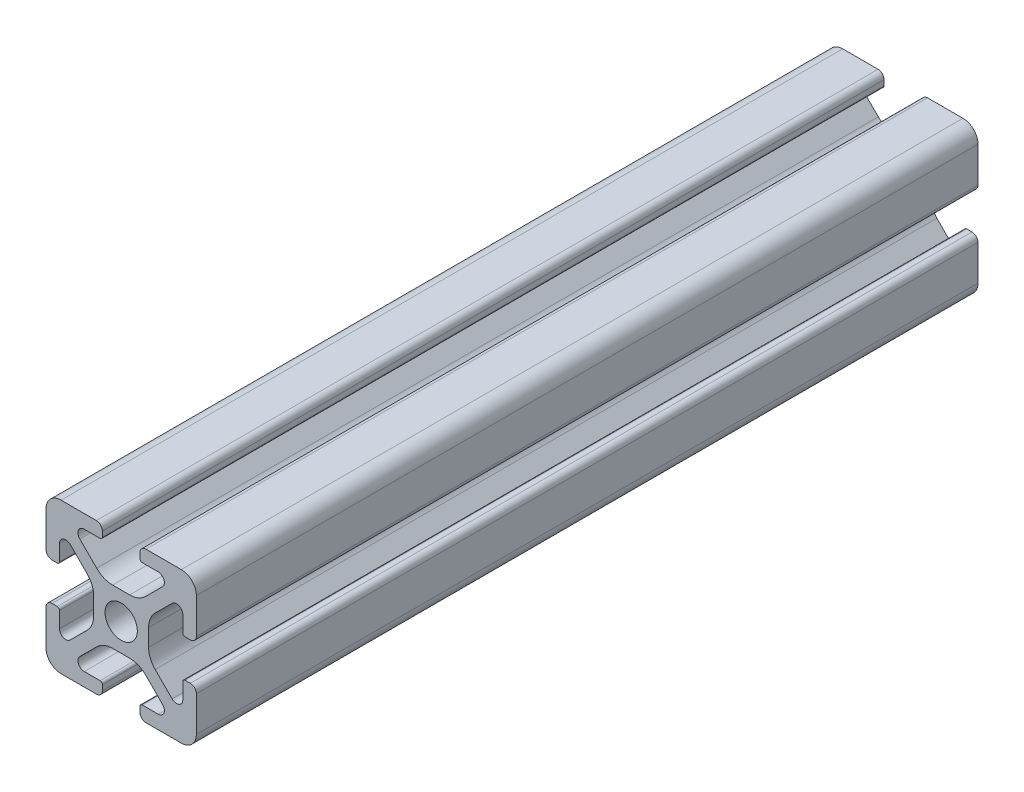
from build123d import *

# Parameters (mm, degrees)
SKIZZE1_R                       = 2.15
AUFSATZ_LINEAR_AUSTRAGEN1_DEPTH = 104


with BuildPart() as part:
    # Skizze1 → Aufsatz-Linear austragen1 (new body)
    with BuildSketch(Plane.XY.offset(100)):
        with BuildLine():
            Line((12.499999989, 1.499999999), (12.499999989, 0.800000002))
            ThreePointArc((12.499999989, 0.800000002), (12.734314564, 0.234314576), (13.299999991, 0))
            Line((13.299999991, 0), (18, 0))
            ThreePointArc((18, 0), (19.414213562, 0.585786438), (20, 2))
            Line((20, 2), (20, 6.700000003))
            ThreePointArc((20, 6.700000003), (19.765685425, 7.265685427), (19.2, 7.500000003))
            Line((19.2, 7.500000003), (18.499999995, 7.500000003))
            ThreePointArc((18.499999995, 7.500000003), (18.287867961, 7.412132037), (18.199999995, 7.200000003))
            Line((18.199999995, 7.200000003), (18.199999995, 5.082411607))
            ThreePointArc((18.199999995, 5.082411607), (17.686138517, 4.313363558), (16.778984491, 4.493807713))
            Line((16.778984491, 4.493807713), (14.528679651, 6.744112553))
            ThreePointArc((14.528679651, 6.744112553), (13.878361397, 7.717382599), (13.649999995, 8.865432896))
            Line((13.649999995, 8.865432896), (13.649999995, 11.134567106))
            ThreePointArc((13.649999995, 11.134567106), (13.878361397, 12.282617403), (14.528679651, 13.255887449))
            Line((14.528679651, 13.255887449), (16.778984493, 15.506192291))
            ThreePointArc((16.778984493, 15.506192291), (17.686138518, 15.686636446), (18.199999995, 14.917588398))
            Line((18.199999995, 14.917588398), (18.199999995, 12.800000001))
            ThreePointArc((18.199999995, 12.800000001), (18.287867961, 12.587867966), (18.499999996, 12.5))
            Line((18.499999996, 12.5), (19.199999998, 12.5))
            ThreePointArc((19.199999998, 12.5), (19.765685424, 12.734314576), (20, 13.300000003))
            Line((20, 13.300000003), (20, 18))
            ThreePointArc((20, 18), (19.414213562, 19.414213562), (18, 20))
            Line((18, 20), (13.299999989, 20))
            ThreePointArc((13.299999989, 20), (12.734314564, 19.765685425), (12.499999989, 19.2))
            Line((12.499999989, 19.2), (12.499999989, 18.499999999))
            ThreePointArc((12.499999989, 18.499999999), (12.587867954, 18.287867964), (12.799999989, 18.199999999))
            Line((12.799999989, 18.199999999), (14.917588395, 18.199999999))
            ThreePointArc((14.917588395, 18.199999999), (15.686636445, 17.68613852), (15.50619229, 16.778984493))
            Line((15.50619229, 16.778984493), (13.255887454, 14.528679658))
            ThreePointArc((13.255887454, 14.528679658), (12.282617408, 13.878361404), (11.134567111, 13.650000002))
            Line((11.134567111, 13.650000002), (8.865432888, 13.650000002))
            ThreePointArc((8.865432888, 13.650000002), (7.717382592, 13.878361404), (6.744112546, 14.528679658))
            Line((6.744112546, 14.528679658), (4.493807706, 16.778984498))
            ThreePointArc((4.493807706, 16.778984498), (4.313363551, 17.686138522), (5.082411599, 18.199999999))
            Line((5.082411599, 18.199999999), (7.199999999, 18.199999999))
            ThreePointArc((7.199999999, 18.199999999), (7.412132034, 18.287867965), (7.5, 18.5))
            Line((7.5, 18.5), (7.5, 19.199999998))
            ThreePointArc((7.5, 19.199999998), (7.265685424, 19.765685424), (6.699999997, 20))
            Line((6.699999997, 20), (2, 20))
            ThreePointArc((2, 20), (0.585786438, 19.414213562), (0, 18))
            Line((0, 18), (0, 13.3))
            ThreePointArc((0, 13.3), (0.234314575, 12.734314575), (0.8, 12.5))
            Line((0.8, 12.5), (1.500000004, 12.5))
            ThreePointArc((1.500000004, 12.5), (1.712132038, 12.587867966), (1.800000004, 12.8))
            Line((1.800000004, 12.8), (1.800000004, 14.917588391))
            ThreePointArc((1.800000004, 14.917588391), (2.313861482, 15.68663644), (3.221015508, 15.506192285))
            Line((3.221015508, 15.506192285), (5.471320345, 13.255887449))
            ThreePointArc((5.471320345, 13.255887449), (6.121638599, 12.282617402), (6.350000001, 11.134567106))
            Line((6.350000001, 11.134567106), (6.350000001, 8.865432891))
            ThreePointArc((6.350000001, 8.865432891), (6.121638599, 7.717382594), (5.471320345, 6.744112548))
            Line((5.471320345, 6.744112548), (3.221015505, 4.493807708))
            ThreePointArc((3.221015505, 4.493807708), (2.313861481, 4.313363554), (1.800000004, 5.082411601))
            Line((1.800000004, 5.082411601), (1.800000004, 7.200000001))
            ThreePointArc((1.800000004, 7.200000001), (1.712132038, 7.412132036), (1.500000003, 7.500000002))
            Line((1.500000003, 7.500000002), (0.800000003, 7.500000002))
            ThreePointArc((0.800000003, 7.500000002), (0.234314576, 7.265685427), (0, 6.7))
            Line((0, 6.7), (0, 2))
            ThreePointArc((0, 2), (0.585786438, 0.585786438), (2, 0))
            Line((2, 0), (6.7, 0))
            ThreePointArc((6.7, 0), (7.265685425, 0.234314575), (7.5, 0.8))
            Line((7.5, 0.8), (7.5, 1.5))
            ThreePointArc((7.5, 1.5), (7.412132034, 1.712132034), (7.2, 1.8))
            Line((7.2, 1.8), (5.0824116, 1.8))
            ThreePointArc((5.0824116, 1.8), (4.313363551, 2.313861478), (4.493807706, 3.221015504))
            Line((4.493807706, 3.221015504), (6.744112546, 5.471320344))
            ThreePointArc((6.744112546, 5.471320344), (7.717382592, 6.121638598), (8.865432889, 6.35))
            Line((8.865432889, 6.35), (11.134567106, 6.35))
            ThreePointArc((11.134567106, 6.35), (12.282617403, 6.121638598), (13.255887449, 5.471320344))
            Line((13.255887449, 5.471320344), (15.506192291, 3.221015502))
            ThreePointArc((15.506192291, 3.221015502), (15.686636446, 2.313861477), (14.917588398, 1.8))
            Line((14.917588398, 1.8), (12.79999999, 1.8))
            ThreePointArc((12.79999999, 1.8), (12.587867955, 1.712132034), (12.499999989, 1.499999999))
        make_face()
        with Locations((10, 10)):
            Circle(SKIZZE1_R, mode=Mode.SUBTRACT)
    extrude(amount=-AUFSATZ_LINEAR_AUSTRAGEN1_DEPTH)


solid = part.part
